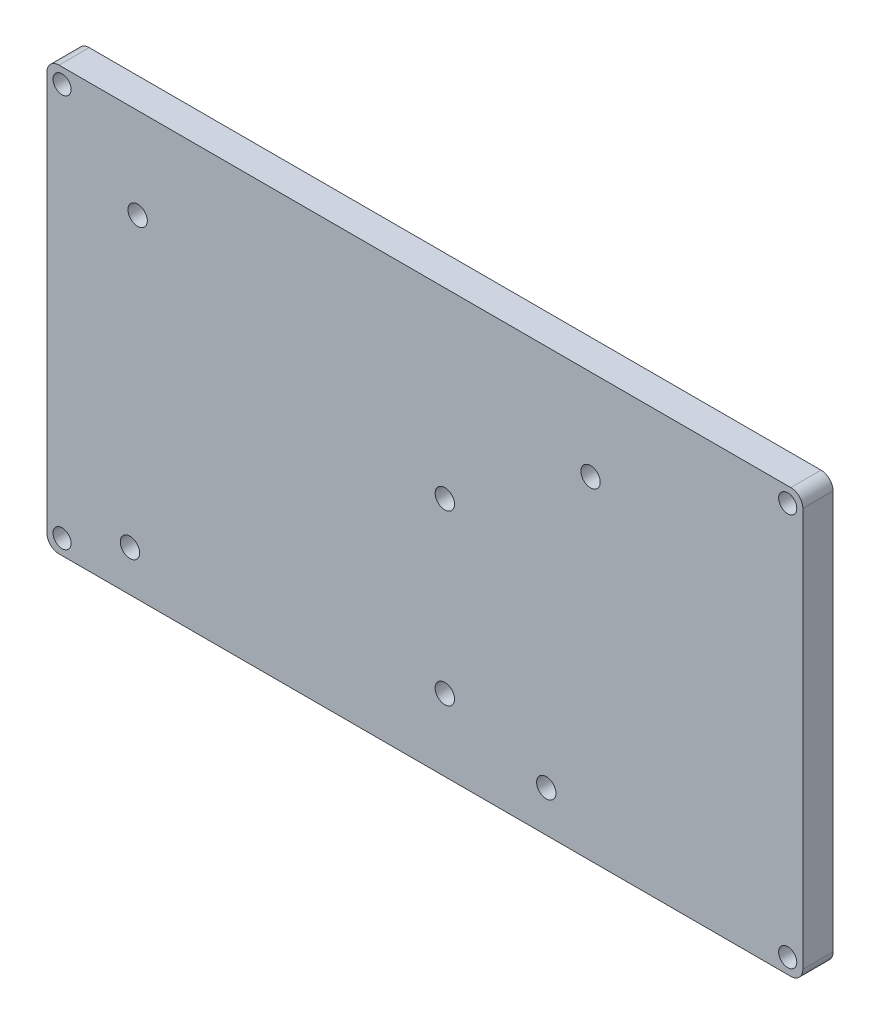
from build123d import *

# Parameters (mm, degrees)
SKETCH1_W           = 125
SKETCH1_H           = 70
SKETCH1_R           = 1.6
SKETCH1_R_2         = 1.5
BOSS_EXTRUDE1_DEPTH = 5
FILLET1_R           = 2


with BuildPart() as part:
    # Sketch1 → Boss-Extrude1 (new body)
    with BuildSketch(Plane.XY):
        with Locations((62.5, 35)):
            Rectangle(SKETCH1_W, SKETCH1_H)
        with Locations((15, 55)):
            Circle(SKETCH1_R, mode=Mode.SUBTRACT)
        with Locations((13.73, 6.8)):
            Circle(SKETCH1_R, mode=Mode.SUBTRACT)
        with Locations((82.573533757, 6.8)):
            Circle(SKETCH1_R, mode=Mode.SUBTRACT)
        with Locations((89.9, 55)):
            Circle(SKETCH1_R, mode=Mode.SUBTRACT)
        with Locations((65.8, 39.8)):
            Circle(SKETCH1_R, mode=Mode.SUBTRACT)
        with Locations((65.8, 11.9)):
            Circle(SKETCH1_R, mode=Mode.SUBTRACT)
        with Locations((2.5, 67.5)):
            Circle(SKETCH1_R_2, mode=Mode.SUBTRACT)
        with Locations((122.5, 67.5)):
            Circle(SKETCH1_R_2, mode=Mode.SUBTRACT)
        with Locations((122.5, 2.5)):
            Circle(SKETCH1_R_2, mode=Mode.SUBTRACT)
        with Locations((2.5, 2.5)):
            Circle(SKETCH1_R_2, mode=Mode.SUBTRACT)
    extrude(amount=BOSS_EXTRUDE1_DEPTH)

    # Fillet1
    fillet1_edges = [part.edges().sort_by_distance(p)[0] for p in [
        (0, 70, 2.5),
        (125, 70, 2.5),
        (125, 0, 2.5),
        (0, 0, 2.5),
    ]]
    fillet(fillet1_edges, radius=FILLET1_R)


solid = part.part
